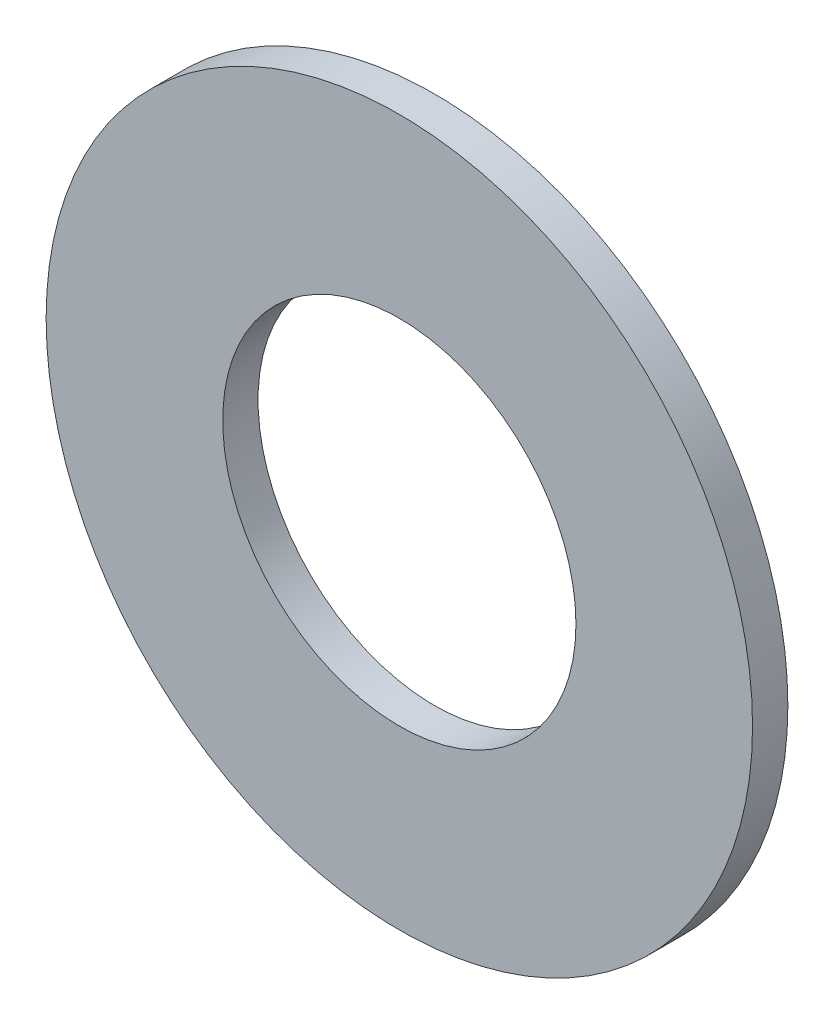
from build123d import *

# Parameters (mm, degrees)
SKETCH1_R           = 10
BOSS_EXTRUDE1_DEPTH = 1
SKETCH2_R           = 5
CUT_EXTRUDE1_DEPTH  = 4


with BuildPart() as part:
    # Sketch1 → Boss-Extrude1 (new body)
    with BuildSketch(Plane.XY):
        Circle(SKETCH1_R)
    extrude(amount=BOSS_EXTRUDE1_DEPTH)

    # Sketch2 → Cut-Extrude1 (cut)
    with BuildSketch(Plane.XY.offset(1)):
        Circle(SKETCH2_R)
    extrude(amount=-CUT_EXTRUDE1_DEPTH, mode=Mode.SUBTRACT)


solid = part.part
